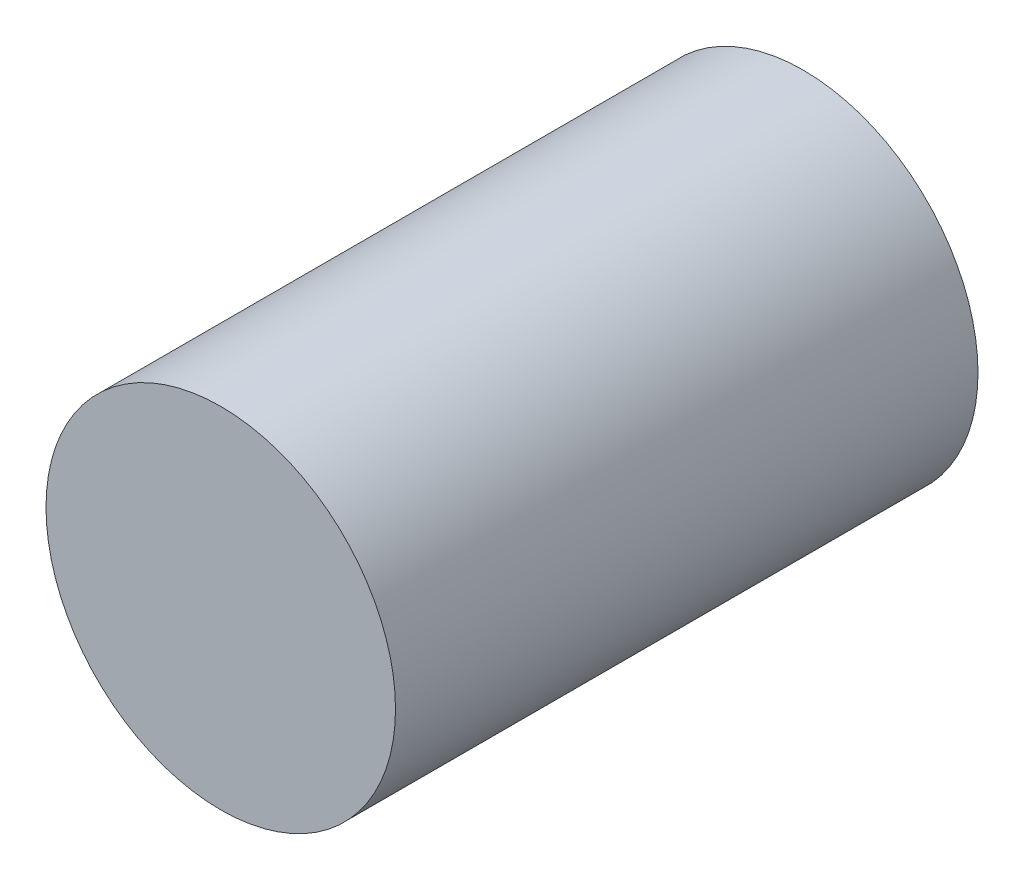
from build123d import *

# Parameters (mm, degrees)
SKETCH1_R           = 3
BOSS_EXTRUDE1_DEPTH = 10


with BuildPart() as part:
    # Sketch1 → Boss-Extrude1 (new body)
    with BuildSketch(Plane.XY):
        Circle(SKETCH1_R)
    extrude(amount=BOSS_EXTRUDE1_DEPTH)


solid = part.part
